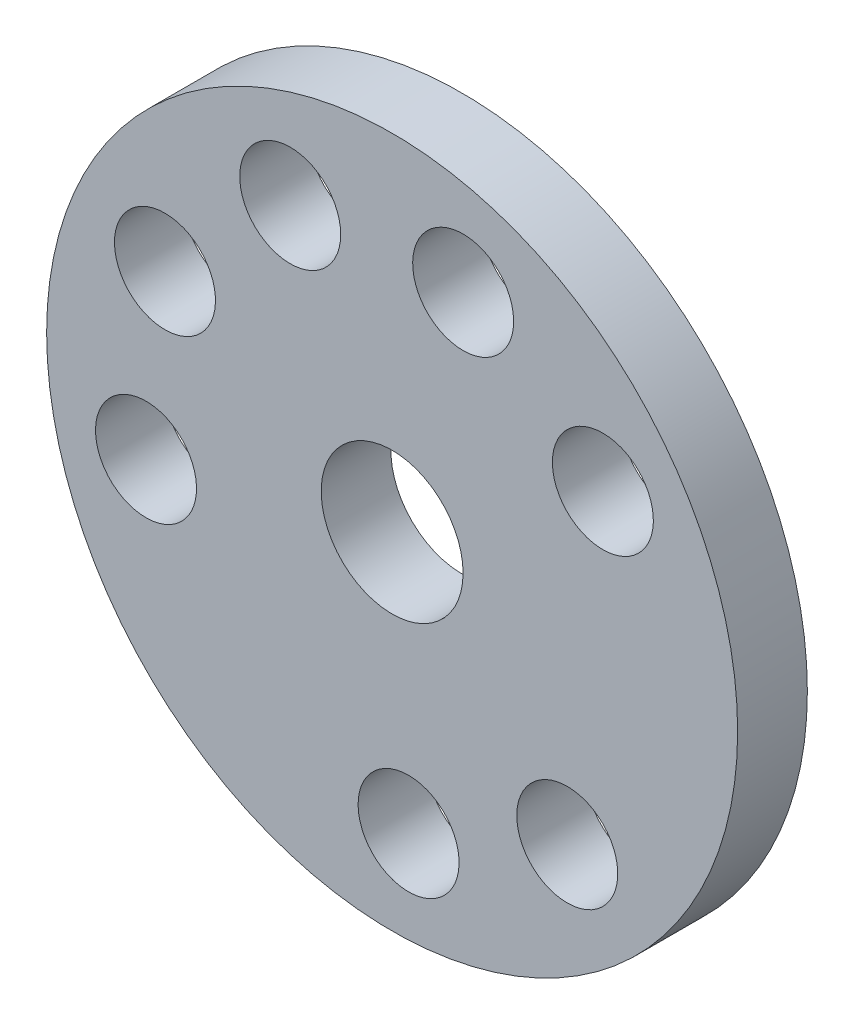
from build123d import *

# Parameters (mm, degrees)
SKETCH8_R           = 49.56483005
BOSS_EXTRUDE3_DEPTH = 10
SKETCH9_R           = 10.176647679
CUT_EXTRUDE3_DEPTH  = 11
SKETCH11_R          = 7.242372995
CUT_EXTRUDE5_DEPTH  = 11
CIRPATTERN2_COUNT   = 9


with BuildPart() as part:
    # Sketch8 → Boss-Extrude3 (new body)
    with BuildSketch(Plane.XY):
        Circle(SKETCH8_R)
    extrude(amount=BOSS_EXTRUDE3_DEPTH)

    # Sketch9 → Cut-Extrude3 (cut, through all)
    with BuildSketch(Plane.XY.offset(10)):
        Circle(SKETCH9_R)
    extrude(amount=-CUT_EXTRUDE3_DEPTH, mode=Mode.SUBTRACT)

    # Sketch11 → Cut-Extrude5 (cut, through all)
    with BuildSketch(Plane.XY.offset(10)):
        with Locations((-14.621394537, 33.273921214)):
            Circle(SKETCH11_R)
    cut_extrude5 = extrude(amount=-CUT_EXTRUDE5_DEPTH, mode=Mode.SUBTRACT)

    # CirPattern2: Cut-Extrude5 ×9 about axis, 2 skipped
    cirpattern2_axis = Axis((0, 0, 0), (0, 0, 1))
    add([cut_extrude5.rotate(cirpattern2_axis, i * 360 / CIRPATTERN2_COUNT) for i in range(1, CIRPATTERN2_COUNT) if i not in (3, 6)], mode=Mode.SUBTRACT)


solid = part.part
